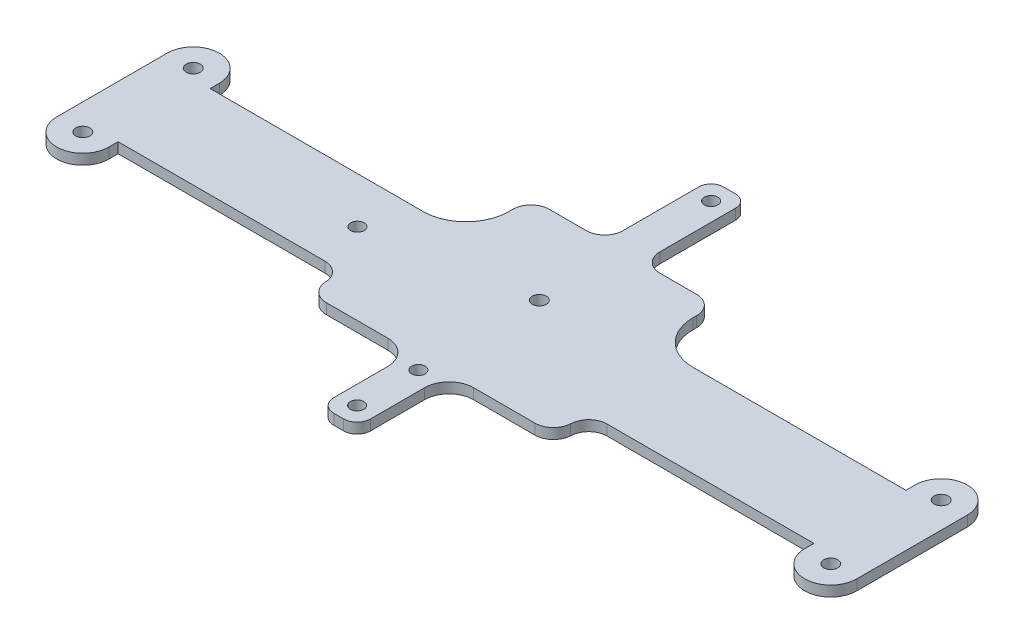
from build123d import *

# Parameters (mm, degrees)
SZKIC1_R                    = 1.15
SZKIC1_R_2                  = 1.150012437
SZKIC1_R_3                  = 1.1
DODANIE_WYCI_GNI_CIE1_DEPTH = 1.7


with BuildPart() as part:
    # Szkic1 → Dodanie-wyciągnięcie1 (new body)
    with BuildSketch(Plane.XZ.offset(-7.087491716)):
        with BuildLine():
            Line((-166.869010382, 45.27), (-166.869010382, 48.27))
            ThreePointArc((-166.869010382, 48.27), (-162.619010382, 52.52), (-158.369010382, 48.27))
            Line((-158.369010382, 48.27), (-158.369010382, 46.77))
            Line((-158.369010382, 46.77), (-124.668997945, 46.77))
            ThreePointArc((-124.668997945, 46.77), (-122.547677602, 47.648679656), (-121.668997945, 49.77))
            Line((-121.668997945, 49.77), (-121.668997945, 49.52))
            ThreePointArc((-121.668997945, 49.52), (-120.790318289, 51.641320344), (-118.668997945, 52.52))
            Line((-118.668997945, 52.52), (-108.668997945, 52.52))
            ThreePointArc((-108.668997945, 52.52), (-105.840570821, 53.691572875), (-104.668997945, 56.52))
            Line((-104.668997945, 56.52), (-104.668997945, 65.32))
            ThreePointArc((-104.668997945, 65.32), (-104.024632864, 66.875634919), (-102.468997945, 67.52))
            Line((-102.468997945, 67.52), (-100.868997945, 67.52))
            ThreePointArc((-100.868997945, 67.52), (-99.313363027, 66.875634919), (-98.668997945, 65.32))
            Line((-98.668997945, 65.32), (-98.668997945, 56.52))
            ThreePointArc((-98.668997945, 56.52), (-97.49742507, 53.691572875), (-94.668997945, 52.52))
            Line((-94.668997945, 52.52), (-84.668997945, 52.52))
            ThreePointArc((-84.668997945, 52.52), (-82.547677602, 51.641320344), (-81.668997945, 49.52))
            Line((-81.668997945, 49.52), (-81.668997945, 49.77))
            ThreePointArc((-81.668997945, 49.77), (-80.790318289, 47.648679656), (-78.668997945, 46.77))
            Line((-78.668997945, 46.77), (-44.968985509, 46.77))
            Line((-44.968985509, 46.77), (-44.968985509, 48.27))
            ThreePointArc((-44.968985509, 48.27), (-40.718985509, 52.52), (-36.468985509, 48.27))
            Line((-36.468985509, 48.27), (-36.468985509, 45.27))
            Line((-36.468985509, 45.27), (-36.468985509, 33.27))
            Line((-36.468985509, 33.27), (-36.468985509, 30.27))
            ThreePointArc((-36.468985509, 30.27), (-40.718985509, 26.02), (-44.968985509, 30.27))
            Line((-44.968985509, 30.27), (-44.968985509, 31.77))
            Line((-44.968985509, 31.77), (-79.668997945, 31.77))
            ThreePointArc((-79.668997945, 31.77), (-84.618745414, 29.719747468), (-86.668997945, 24.77))
            Line((-86.668997945, 24.77), (-86.668997945, 24.17))
            ThreePointArc((-86.668997945, 24.17), (-87.547677602, 22.048679656), (-89.668997945, 21.17))
            Line((-89.668997945, 21.17), (-95.668997945, 21.17))
            ThreePointArc((-95.668997945, 21.17), (-97.790318289, 20.291320344), (-98.668997945, 18.17))
            Line((-98.668997945, 18.17), (-98.668997945, 5.82))
            ThreePointArc((-98.668997945, 5.82), (-99.254784383, 4.405786438), (-100.668997945, 3.82))
            Line((-100.668997945, 3.82), (-102.668997945, 3.82))
            ThreePointArc((-102.668997945, 3.82), (-104.083211508, 4.405786438), (-104.668997945, 5.82))
            Line((-104.668997945, 5.82), (-104.668997945, 18.17))
            ThreePointArc((-104.668997945, 18.17), (-105.547677602, 20.291320344), (-107.668997945, 21.17))
            Line((-107.668997945, 21.17), (-113.668997945, 21.17))
            ThreePointArc((-113.668997945, 21.17), (-115.790318289, 22.048679656), (-116.668997945, 24.17))
            Line((-116.668997945, 24.17), (-116.668997945, 24.77))
            ThreePointArc((-116.668997945, 24.77), (-118.719250477, 29.719747468), (-123.668997945, 31.77))
            Line((-123.668997945, 31.77), (-158.369010382, 31.77))
            Line((-158.369010382, 31.77), (-158.369010382, 30.27))
            ThreePointArc((-158.369010382, 30.27), (-162.619010382, 26.02), (-166.869010382, 30.27))
            Line((-166.869010382, 30.27), (-166.869010382, 33.27))
            Line((-166.869010382, 33.27), (-166.869010382, 45.27))
        make_face()
        with Locations((-162.618997945, 30.27)):
            Circle(SZKIC1_R, mode=Mode.SUBTRACT)
        with Locations((-162.618997945, 48.27)):
            Circle(SZKIC1_R, mode=Mode.SUBTRACT)
        with Locations((-40.718985509, 48.27)):
            Circle(SZKIC1_R_2, mode=Mode.SUBTRACT)
        with Locations((-40.718985509, 30.27)):
            Circle(SZKIC1_R_2, mode=Mode.SUBTRACT)
        with Locations((-101.668997945, 6.82)):
            Circle(SZKIC1_R_3, mode=Mode.SUBTRACT)
        with Locations((-126.869010382, 39.27)):
            Circle(SZKIC1_R_3, mode=Mode.SUBTRACT)
        with Locations((-101.668997945, 54.52)):
            Circle(SZKIC1_R_3, mode=Mode.SUBTRACT)
        with Locations((-101.668997945, 64.52)):
            Circle(SZKIC1_R_3, mode=Mode.SUBTRACT)
        with Locations((-101.668997945, 34.82)):
            Circle(SZKIC1_R, mode=Mode.SUBTRACT)
    extrude(amount=DODANIE_WYCI_GNI_CIE1_DEPTH)


solid = part.part
